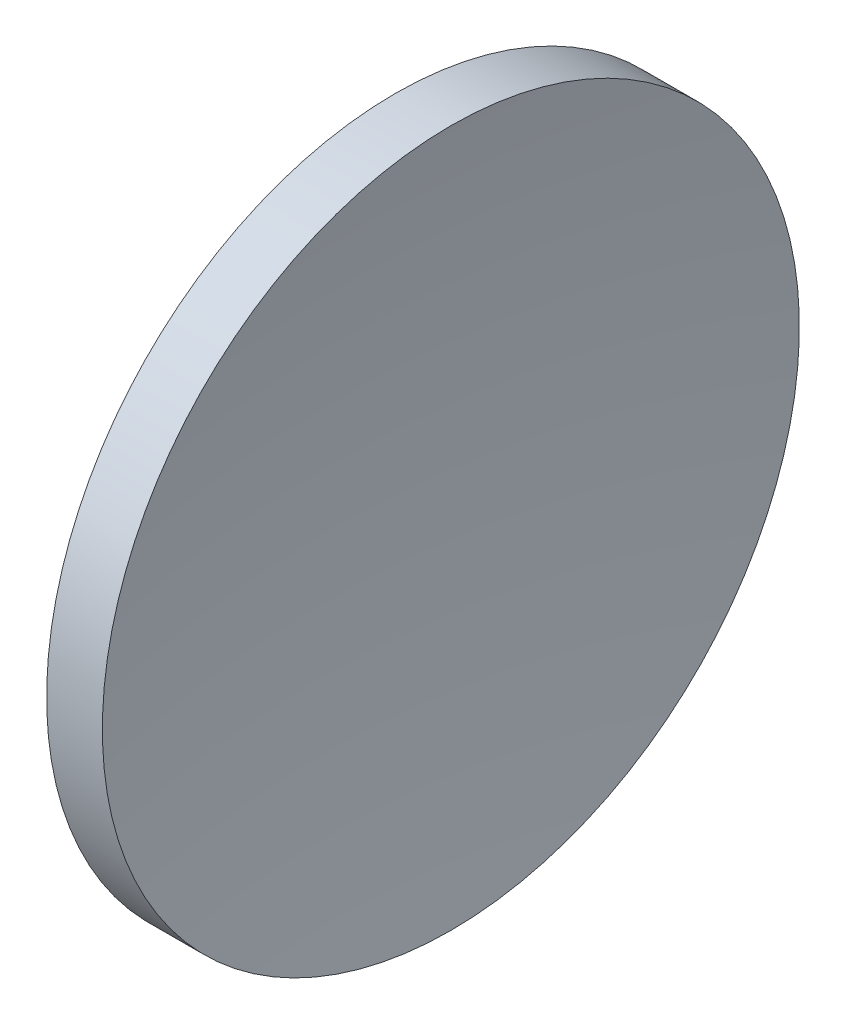
from build123d import *


with BuildPart() as part:
    # 草图1 → 旋转1 (revolve)
    with BuildSketch(Plane.XY):
        with BuildLine():
            Line((248.160541243, 155.433680942), (252.157991512, 155.433680942))
            ThreePointArc((252.157991512, 155.433680942), (250.689494129, 142.971998858), (250.198995672, 130.433680942))
            Line((250.198995672, 130.433680942), (245.198995672, 130.433680942))
            ThreePointArc((245.198995672, 130.433680942), (245.941961495, 143.021082899), (248.160541243, 155.433680942))
        make_face()
    revolve(axis=Axis((231.888982596, 130.433680942, 0), (1, 0, 0)))


solid = part.part
